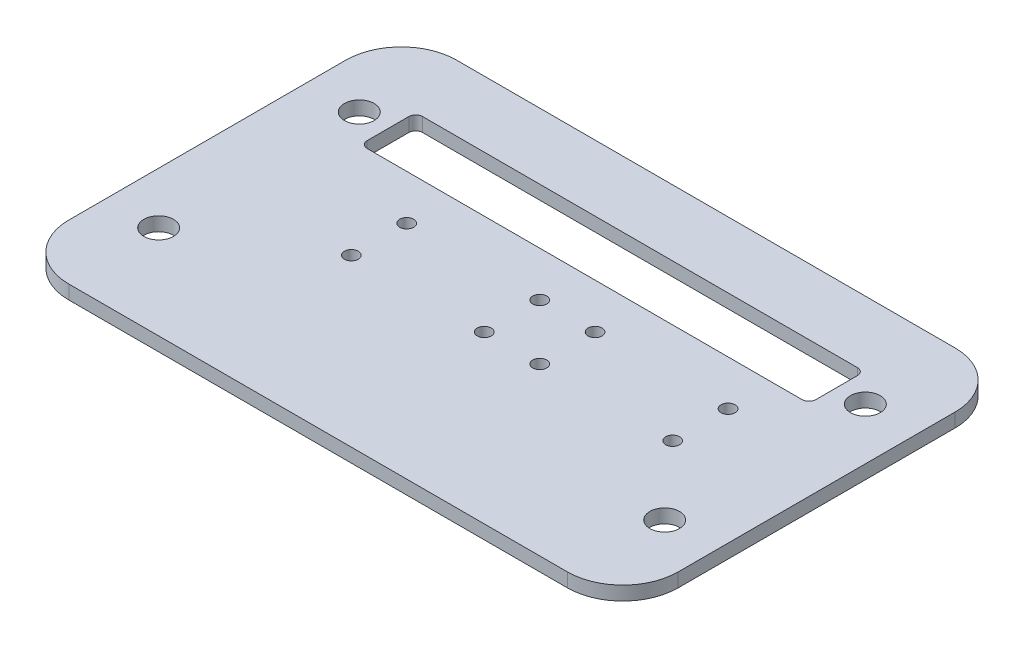
from build123d import *

# Parameters (mm, degrees)
SKETCH3_W                   = 69.85
SKETCH3_H                   = 44.45
BOSS_EXTRUDE1_DEPTH         = 1.5875
M3_CLEARANCE_HOLE1_D        = 3.4
TAP_DRILL_FOR_M2X0_4_TAP1_D = 1.6
FILLET1_R                   = 6.35
SKETCH8_W                   = 51.425
SKETCH8_H                   = 6.35
CUT_EXTRUDE1_DEPTH          = 2.5875
FILLET2_R                   = 0.79375


with BuildPart() as part:
    # Sketch3 → Boss-Extrude1 (new body)
    with BuildSketch(Plane(origin=(0, 0, 0), x_dir=(1, 0, 0), z_dir=(0, 1, 0))):
        Rectangle(SKETCH3_W, SKETCH3_H)
    extrude(amount=BOSS_EXTRUDE1_DEPTH)

    # M3 Clearance Hole1 (through all)
    with Locations(Plane(origin=(0, 1.5875, 0), x_dir=(1, 0, 0), z_dir=(0, 1, 0))):
        with Locations((-29, 11.5), (-29, -11.5), (29, -11.5), (29, 11.5)):
            Hole(M3_CLEARANCE_HOLE1_D / 2)

    # Tap Drill for M2x0.4 Tap1 (through all)
    with Locations(Plane(origin=(0, 1.5875, 0), x_dir=(1, 0, 0), z_dir=(0, 1, 0))):
        with Locations((21.59, -3.175), (-15.24, 3.175), (0, 3.175), (-15.24, -3.175), (0, -3.175), (6.35, 3.175), (21.59, 3.175), (6.35, -3.175)):
            Hole(TAP_DRILL_FOR_M2X0_4_TAP1_D / 2)

    # Fillet1
    fillet1_edges = [part.edges().sort_by_distance(p)[0] for p in [
        (34.925, 0.79375, 22.225),
        (-34.925, 0.79375, 22.225),
        (-34.925, 0.79375, -22.225),
        (34.925, 0.79375, -22.225),
    ]]
    fillet(fillet1_edges, radius=FILLET1_R)

    # Sketch8 → Cut-Extrude1 (cut, through all)
    with BuildSketch(Plane(origin=(0, 1.5875, 0), x_dir=(1, 0, 0), z_dir=(0, 1, 0))):
        with Locations((0, 11.5)):
            Rectangle(SKETCH8_W, SKETCH8_H)
    extrude(amount=-CUT_EXTRUDE1_DEPTH, mode=Mode.SUBTRACT)

    # Fillet2
    fillet2_edges = [part.edges().sort_by_distance(p)[0] for p in [
        (-25.7125, 0.79375, -8.325),
        (-25.7125, 0.79375, -14.675),
        (25.7125, 0.79375, -14.675),
        (25.7125, 0.79375, -8.325),
    ]]
    fillet(fillet2_edges, radius=FILLET2_R)


solid = part.part
